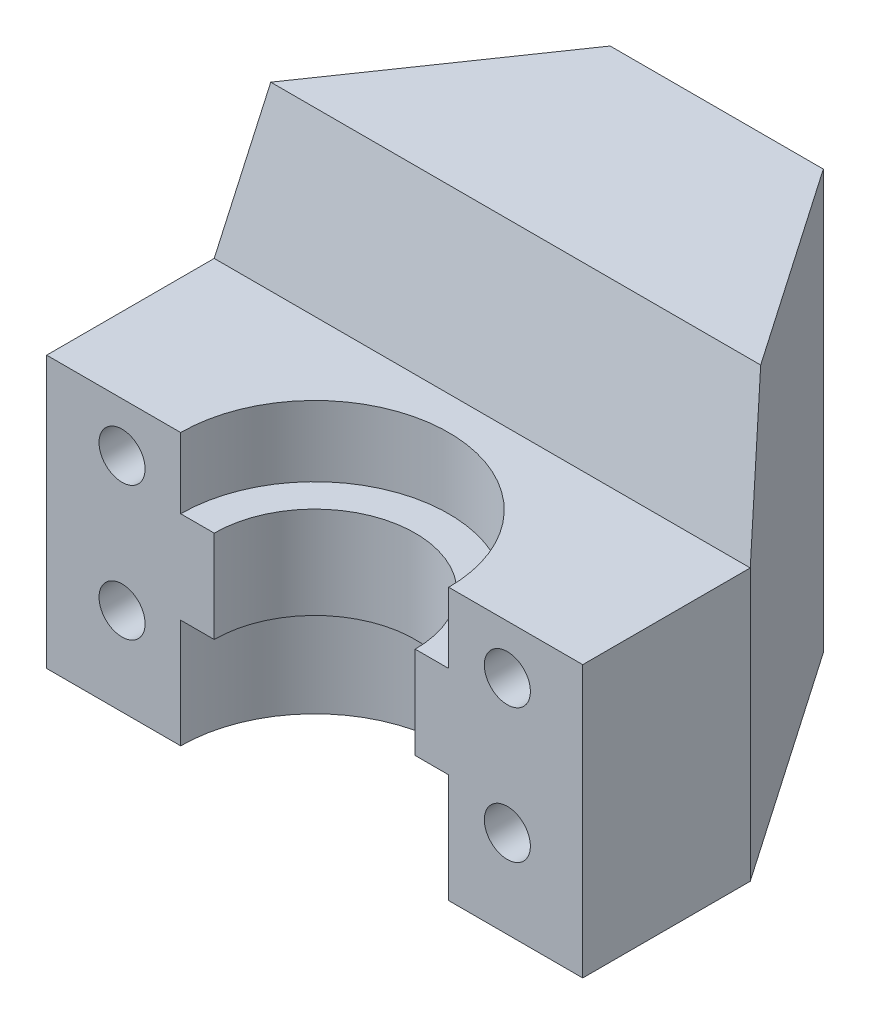
from build123d import *

# Parameters (mm, degrees)
SKETCH1_W                 = 12
SKETCH1_H                 = 25
BOSS_EXTRUDE1_DEPTH       = 16
SKETCH2_W                 = 32
SKETCH2_H                 = 10
BOSS_EXTRUDE2_DEPTH       = 16.2
BOSS_EXTRUDE3_DEPTH       = 32
M5X0_8_TAPPED_HOLE1_D     = 4.2
M5X0_8_TAPPED_HOLE1_DEPTH = 9
M5X0_8_TAPPED_HOLE1_TIP   = 1.2618073
CUT_EXTRUDE2_REACH        = 27
M3X0_5_TAPPED_HOLE1_D     = 2.75
M3X0_5_TAPPED_HOLE1_DEPTH = 12
M3X0_5_TAPPED_HOLE1_TIP   = 0.826183351


with BuildPart() as part:
    # Sketch1 → Boss-Extrude1 (new body, symmetric)
    with BuildSketch(Plane(origin=(0, 0, 0), x_dir=(0, 0, -1), z_dir=(1, 0, 0))):
        with Locations((6, 12.5)):
            Rectangle(SKETCH1_W, SKETCH1_H)
    extrude(amount=BOSS_EXTRUDE1_DEPTH, both=True)



with BuildPart() as body_2:
    # Sketch2 → Boss-Extrude2 (new body)
    with BuildSketch(Plane(origin=(0, 0, 0), x_dir=(1, 0, 0), z_dir=(0, 1, 0))):
        with Locations((0, -7)):
            Rectangle(SKETCH2_W, SKETCH2_H)
    extrude(amount=BOSS_EXTRUDE2_DEPTH)


with BuildPart() as part_1:
    add(part.part)

    add(body_2.part)  # Boss-Extrude3 merges body 2
    # Sketch3 → Boss-Extrude3 (add)
    with BuildSketch(Plane(origin=(16, 0, 0), x_dir=(0, 0, -1), z_dir=(1, 0, 0))):
        Polygon((-2, 0), (-2, 16.2), (0, 25), (0, 0), align=None)
    extrude(amount=-BOSS_EXTRUDE3_DEPTH)

    # M5x0.8 Tapped Hole1
    with Locations(Plane(origin=(0, 0, -12), x_dir=(-1, 0, 0), z_dir=(0, 0, -1))):
        with Locations((0, 20), (0, 5)):
            Hole(M5X0_8_TAPPED_HOLE1_D / 2, depth=M5X0_8_TAPPED_HOLE1_DEPTH)
            with Locations((0, 0, -(M5X0_8_TAPPED_HOLE1_DEPTH + M5X0_8_TAPPED_HOLE1_TIP / 2))):  # 118° drill point
                Cone(0, M5X0_8_TAPPED_HOLE1_D / 2, M5X0_8_TAPPED_HOLE1_TIP, mode=Mode.SUBTRACT)

    # Sketch9 → Cut-Revolve1 (revolve, cut)
    with BuildSketch(Plane(origin=(0, 0, 0), x_dir=(0, 0, -1), z_dir=(1, 0, 0))):
        Polygon((-12, 16.2), (-4, 16.2), (-4, 12), (-6, 12), (-6, 6.5), (-4, 6.5), (-4, 0), (-12, 0), align=None)
    revolve(axis=Axis((0, 0, 12), (0, 1, 0)), mode=Mode.SUBTRACT)

    # Sketch10 → Cut-Extrude2 (cut, up to next)
    with BuildSketch(Plane(origin=(0, 25, 0), x_dir=(1, 0, 0), z_dir=(0, 1, 0)), mode=Mode.PRIVATE) as cut_extrude2_sk1:
        Polygon((6.3625, 12), (14.623214286, 0), (16, 0), (16, 12), align=None)
    cut_extrude2_tool1 = extrude(cut_extrude2_sk1.sketch, amount=-CUT_EXTRUDE2_REACH, mode=Mode.PRIVATE) & part_1.part
    add(cut_extrude2_tool1.solids().sort_by_distance((12.730134, 25, -7.5))[0], mode=Mode.SUBTRACT)
    # Sketch10 → Cut-Extrude2 (cut, up to next)
    with BuildSketch(Plane(origin=(0, 25, 0), x_dir=(1, 0, 0), z_dir=(0, 1, 0)), mode=Mode.PRIVATE) as cut_extrude2_sk2:
        Polygon((16, 0), (14.623214286, 0), (16, -2), align=None)
    cut_extrude2_tool2 = extrude(cut_extrude2_sk2.sketch, amount=-CUT_EXTRUDE2_REACH, mode=Mode.PRIVATE) & part_1.part
    add(cut_extrude2_tool2.solids().sort_by_distance((15.541071, 25, 0.666667))[0], mode=Mode.SUBTRACT)
    # Sketch10 → Cut-Extrude2 (cut, up to next)
    with BuildSketch(Plane(origin=(0, 25, 0), x_dir=(1, 0, 0), z_dir=(0, 1, 0)), mode=Mode.PRIVATE) as cut_extrude2_sk3:
        Polygon((-16, 0), (-14.623214286, 0), (-6.3625, 12), (-16, 12), align=None)
    cut_extrude2_tool3 = extrude(cut_extrude2_sk3.sketch, amount=-CUT_EXTRUDE2_REACH, mode=Mode.PRIVATE) & part_1.part
    add(cut_extrude2_tool3.solids().sort_by_distance((-12.730134, 25, -7.5))[0], mode=Mode.SUBTRACT)
    # Sketch10 → Cut-Extrude2 (cut, up to next)
    with BuildSketch(Plane(origin=(0, 25, 0), x_dir=(1, 0, 0), z_dir=(0, 1, 0)), mode=Mode.PRIVATE) as cut_extrude2_sk4:
        Polygon((-16, 0), (-16, -2), (-14.623214286, 0), align=None)
    cut_extrude2_tool4 = extrude(cut_extrude2_sk4.sketch, amount=-CUT_EXTRUDE2_REACH, mode=Mode.PRIVATE) & part_1.part
    add(cut_extrude2_tool4.solids().sort_by_distance((-15.541071, 25, 0.666667))[0], mode=Mode.SUBTRACT)

    # M3x0.5 Tapped Hole1
    with Locations(Plane.XY.offset(12)):
        with Locations((-11.5, 13.25), (11.5, 13.25), (-11.5, 5.25), (11.5, 5.25)):
            Hole(M3X0_5_TAPPED_HOLE1_D / 2, depth=M3X0_5_TAPPED_HOLE1_DEPTH)
            with Locations((0, 0, -(M3X0_5_TAPPED_HOLE1_DEPTH + M3X0_5_TAPPED_HOLE1_TIP / 2))):  # 118° drill point
                Cone(0, M3X0_5_TAPPED_HOLE1_D / 2, M3X0_5_TAPPED_HOLE1_TIP, mode=Mode.SUBTRACT)


solid = part_1.part
